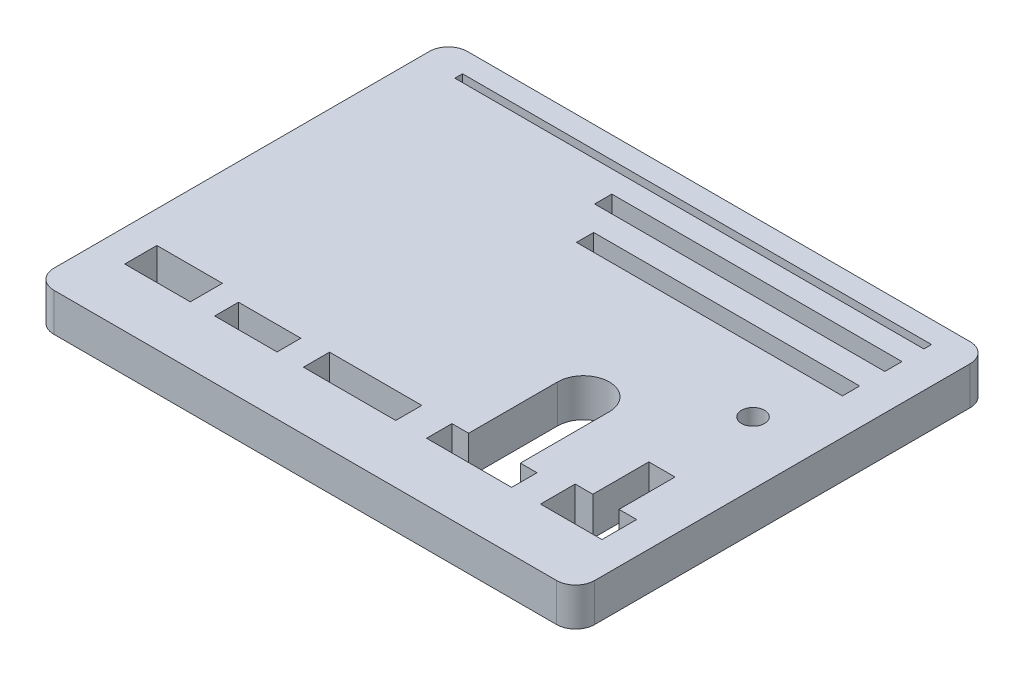
from build123d import *

# Parameters (mm, degrees)
SKETCH1_W           = 85
SKETCH1_H           = 65
SKETCH1_R           = 1.81
SKETCH1_W_2         = 14.5
SKETCH1_H_2         = 4.1
SKETCH1_W_3         = 9.8
SKETCH1_H_3         = 3.74
SKETCH1_W_4         = 10.3
SKETCH1_H_4         = 5.05
SKETCH1_W_5         = 73.7
SKETCH1_H_5         = 1.2
SKETCH1_W_6         = 45.6
SKETCH1_H_6         = 2.7
SKETCH1_W_7         = 41.8
BOSS_EXTRUDE1_DEPTH = 6
FILLET1_R           = 3


with BuildPart() as part:
    # Sketch1 → Boss-Extrude1 (new body)
    with BuildSketch(Plane(origin=(0, 0, 0), x_dir=(1, 0, 0), z_dir=(0, 1, 0))):
        Rectangle(SKETCH1_W, SKETCH1_H)
        with Locations((32.67, 5.206342289)):
            Circle(SKETCH1_R, mode=Mode.SUBTRACT)
        Polygon((37.5, -23.359842136), (27.84, -23.359842136), (27.84, -17.909842136), (30.61, -17.909842136), (30.61, -9.109842136), (34.73, -9.109842136), (34.73, -17.909842136), (37.5, -17.909842136), align=None, mode=Mode.SUBTRACT)
        with BuildLine():
            Line((23.3025, -23.359842136), (9.9325, -23.359842136))
            Line((9.9325, -23.359842136), (9.9325, -19.369842136))
            Line((9.9325, -19.369842136), (12.5525, -19.369842136))
            Line((12.5525, -19.369842136), (12.5525, -5.394842136))
            ThreePointArc((12.5525, -5.394842136), (16.6175, -1.329842136), (20.6825, -5.394842136))
            Line((20.6825, -5.394842136), (20.6825, -19.369842136))
            Line((20.6825, -19.369842136), (23.3025, -19.369842136))
            Line((23.3025, -19.369842136), (23.3025, -23.359842136))
        make_face(mode=Mode.SUBTRACT)
        with Locations((-2.165, -21.309842136)):
            Rectangle(SKETCH1_W_2, SKETCH1_H_2, mode=Mode.SUBTRACT)
        with Locations((-18.4625, -21.489842136)):
            Rectangle(SKETCH1_W_3, SKETCH1_H_3, mode=Mode.SUBTRACT)
        with Locations((-32.35, -20.834842136)):
            Rectangle(SKETCH1_W_4, SKETCH1_H_4, mode=Mode.SUBTRACT)
        with Locations((0, 28.473253228)):
            Rectangle(SKETCH1_W_5, SKETCH1_H_5, mode=Mode.SUBTRACT)
        with Locations((14.05, 23.086178608)):
            Rectangle(SKETCH1_W_6, SKETCH1_H_6, mode=Mode.SUBTRACT)
        with Locations((15.95, 16.43449293)):
            Rectangle(SKETCH1_W_7, SKETCH1_H_6, mode=Mode.SUBTRACT)
    extrude(amount=BOSS_EXTRUDE1_DEPTH)

    # Fillet1
    fillet1_edges = [part.edges().sort_by_distance(p)[0] for p in [
        (42.5, 3, 32.5),
        (-42.5, 3, 32.5),
        (-42.5, 3, -32.5),
        (42.5, 3, -32.5),
    ]]
    fillet(fillet1_edges, radius=FILLET1_R)


solid = part.part
